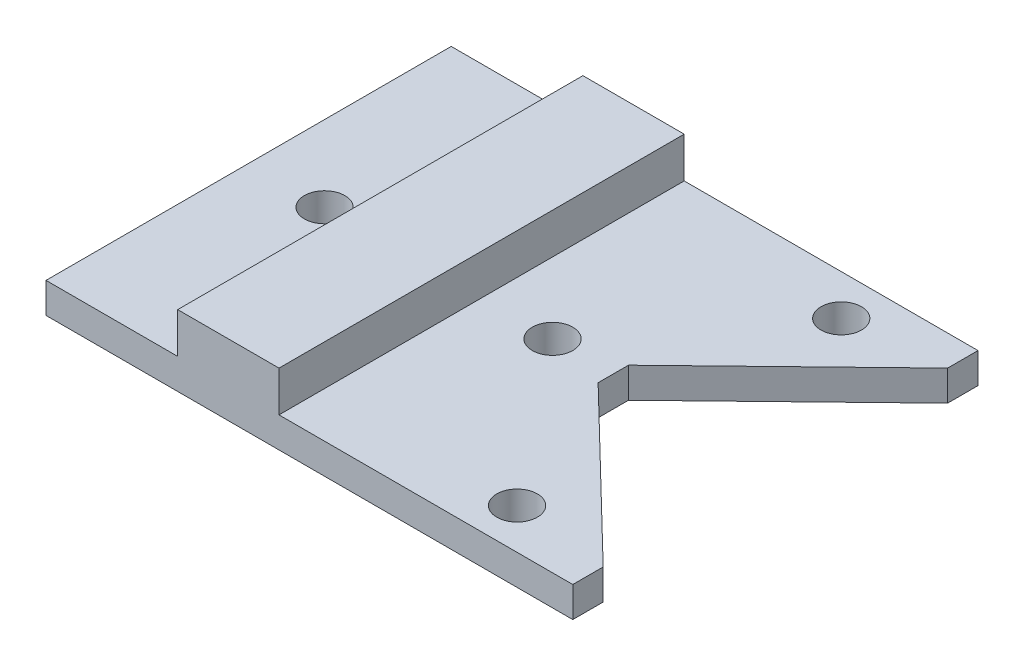
from build123d import *

# Parameters (mm, degrees)
BASE_DEPTH       = 3
BULDGESKETCH_W   = 10
BULDGESKETCH_H   = 40
BULDGE_DEPTH     = 4
HOLESSKETCH_R    = 2
HOLES_DEPTH      = 1
HOLES_DEPTH_BACK = 8


with BuildPart() as part:
    # BaseSketch → Base (new body)
    with BuildSketch(Plane(origin=(0, 0, 0), x_dir=(1, 0, 0), z_dir=(0, 1, 0))):
        Polygon((26, -20), (26, -17), (10, -1.5), (10, 1.5), (26, 17), (26, 20), (-26, 20), (-26, -20), align=None)
    extrude(amount=BASE_DEPTH)

    # BuldgeSketch → Buldge (add)
    with BuildSketch(Plane(origin=(0, 3, 0), x_dir=(1, 0, 0), z_dir=(0, 1, 0))):
        with Locations((-8, 0)):
            Rectangle(BULDGESKETCH_W, BULDGESKETCH_H)
    extrude(amount=BULDGE_DEPTH)

    # HolesSketch → Holes (cut, two sides)
    with BuildSketch(Plane.XZ) as holes_sk:
        with Locations((4, 0)):
            Circle(HOLESSKETCH_R)
        with Locations((16.5, -16)):
            Circle(HOLESSKETCH_R)
        with Locations((16.5, 16)):
            Circle(HOLESSKETCH_R)
        with Locations((-18.5, 0)):
            Circle(HOLESSKETCH_R)
    extrude(amount=HOLES_DEPTH, mode=Mode.SUBTRACT)
    extrude(holes_sk.sketch, amount=-HOLES_DEPTH_BACK, mode=Mode.SUBTRACT)


solid = part.part
